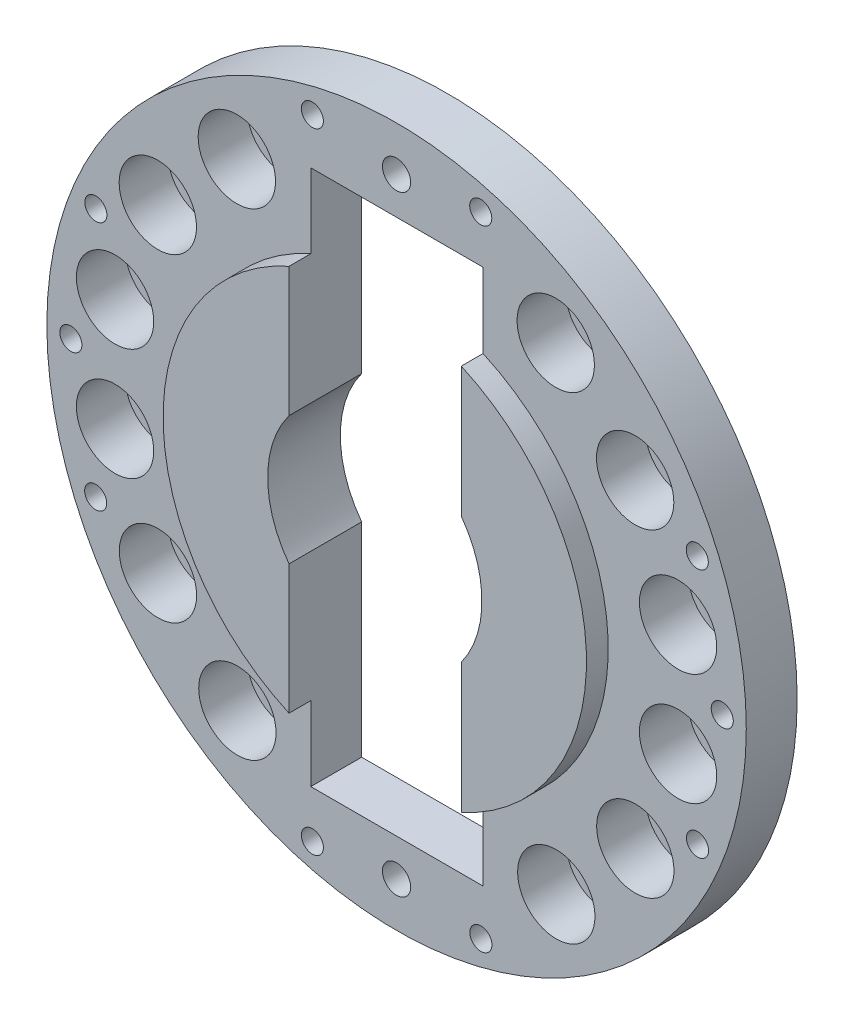
from build123d import *

# Parameters (mm, degrees)
SKETCH1_R                      = 272.79346
SKETCH1_R_2                    = 30.1625
SKETCH1_R_3                    = 8.617585
SKETCH1_R_4                    = 11.00963
SKETCH1_R_5                    = 164.44976
SKETCH1_R_6                    = 83.56346
EXTRUDE5_DEPTH                 = 39.69258
EXTRUDE8_DEPTH                 = 16.97482
SKETCH4_W                      = 134.3533
SKETCH4_H                      = 418.01542
EXTRUDE10_DEPTH                = 64.83223
SKETCH7_R                      = 30.1625
EXTRUDE12_DEPTH                = 1.59258
F_1_8_TAPPED_HOLE1_D           = 22.225
F_1_8_TAPPED_HOLE1_ON_FACE_2_D = 22.225


with BuildPart() as part:
    # Sketch1 → Extrude5 (new body)
    with BuildSketch(Plane.XY):
        Circle(SKETCH1_R)
        with Locations((219.584848865, -43.672962802)):
            Circle(SKETCH1_R_2, mode=Mode.SUBTRACT)
        with Locations((-219.57722315, 43.711286923)):
            Circle(SKETCH1_R_2, mode=Mode.SUBTRACT)
        with Locations((186.220609513, -124.284826602)):
            Circle(SKETCH1_R_2, mode=Mode.SUBTRACT)
        with Locations((-186.220609513, 124.284826602)):
            Circle(SKETCH1_R_2, mode=Mode.SUBTRACT)
        with Locations((124.588226536, -186.017760817)):
            Circle(SKETCH1_R_2, mode=Mode.SUBTRACT)
        with Locations((-124.588226536, 186.017760817)):
            Circle(SKETCH1_R_2, mode=Mode.SUBTRACT)
        with Locations((-124.160317609, -186.303647474)):
            Circle(SKETCH1_R_2, mode=Mode.SUBTRACT)
        with Locations((124.160317609, 186.303647474)):
            Circle(SKETCH1_R_2, mode=Mode.SUBTRACT)
        with Locations((-186.104477248, -124.458656103)):
            Circle(SKETCH1_R_2, mode=Mode.SUBTRACT)
        with Locations((186.104477248, 124.458656103)):
            Circle(SKETCH1_R_2, mode=Mode.SUBTRACT)
        with Locations((219.584848865, 43.672962802)):
            Circle(SKETCH1_R_2, mode=Mode.SUBTRACT)
        with Locations((-219.584848865, -43.672962802)):
            Circle(SKETCH1_R_2, mode=Mode.SUBTRACT)
        with Locations((-234.688092884, -97.272902019)):
            Circle(SKETCH1_R_3, mode=Mode.SUBTRACT)
        with Locations((-65.668151158, -245.414368635)):
            Circle(SKETCH1_R_3, mode=Mode.SUBTRACT)
        with Locations((65.779081624, -245.384658913)):
            Circle(SKETCH1_R_3, mode=Mode.SUBTRACT)
        with Locations((234.735092644, -97.159429242)):
            Circle(SKETCH1_R_3, mode=Mode.SUBTRACT)
        with Locations((-234.564955174, 97.569463528)):
            Circle(SKETCH1_R_3, mode=Mode.SUBTRACT)
        with Locations((-65.668151158, 245.414368635)):
            Circle(SKETCH1_R_3, mode=Mode.SUBTRACT)
        with Locations((65.668151158, 245.414368635)):
            Circle(SKETCH1_R_3, mode=Mode.SUBTRACT)
        with Locations((234.564955174, 97.569463528)):
            Circle(SKETCH1_R_3, mode=Mode.SUBTRACT)
        with Locations((254.04826, 0)):
            Circle(SKETCH1_R_3, mode=Mode.SUBTRACT)
        with Locations((-254.04826, 0)):
            Circle(SKETCH1_R_3, mode=Mode.SUBTRACT)
        with Locations((0, -238.00054)):
            Circle(SKETCH1_R_4, mode=Mode.SUBTRACT)
        with Locations((0, 238.00054)):
            Circle(SKETCH1_R_4, mode=Mode.SUBTRACT)
        Circle(SKETCH1_R_5, mode=Mode.SUBTRACT)
        Circle(SKETCH1_R_5)
        Circle(SKETCH1_R_6, mode=Mode.SUBTRACT)
    extrude(amount=EXTRUDE5_DEPTH)

    # Sketch3 → Extrude8 (add)
    with BuildSketch(Plane.XY.offset(39.69258)):
        with BuildLine():
            Line((-66.9036, 150.950693964), (-66.9036, 50.067555904))
            ThreePointArc((-66.9036, 50.067555904), (-83.56346, 0), (-66.9036, -50.067555904))
            Line((-66.9036, -50.067555904), (-66.9036, -150.950693964))
            ThreePointArc((-66.9036, -150.950693964), (-165.1127, 0), (-66.9036, 150.950693964))
        make_face()
        with BuildLine():
            Line((67.4497, 150.707470522), (67.4497, 49.329401143))
            ThreePointArc((67.4497, 49.329401143), (83.56346, 0), (67.4497, -49.329401143))
            Line((67.4497, -49.329401143), (67.4497, -150.707470522))
            ThreePointArc((67.4497, -150.707470522), (165.1127, 0), (67.4497, 150.707470522))
        make_face()
    extrude(amount=EXTRUDE8_DEPTH)

    # Sketch4 → Extrude10 (cut)
    with BuildSketch(Plane.XY.offset(56.6674)):
        with Locations((0.27305, 0)):
            Rectangle(SKETCH4_W, SKETCH4_H)
    extrude(amount=-EXTRUDE10_DEPTH, mode=Mode.SUBTRACT)

    # Sketch7 → Extrude12 (add)
    with BuildSketch(Plane(origin=(0, 0, 0), x_dir=(-1, 0, 0), z_dir=(0, 0, -1))):
        with Locations((-124.160317609, 186.303647474)):
            Circle(SKETCH7_R)
        with Locations((-186.104477248, 124.458656103)):
            Circle(SKETCH7_R)
        with Locations((-219.584848865, 43.672962802)):
            Circle(SKETCH7_R)
        with Locations((-219.584848865, -43.672962802)):
            Circle(SKETCH7_R)
        with Locations((-186.220609513, -124.284826602)):
            Circle(SKETCH7_R)
        with Locations((-124.588226536, -186.017760817)):
            Circle(SKETCH7_R)
        with Locations((124.160317609, -186.303647474)):
            Circle(SKETCH7_R)
        with Locations((186.104477248, -124.458656103)):
            Circle(SKETCH7_R)
        with Locations((219.584848865, -43.672962802)):
            Circle(SKETCH7_R)
        with Locations((219.57722315, 43.711286923)):
            Circle(SKETCH7_R)
        with Locations((186.220609513, 124.284826602)):
            Circle(SKETCH7_R)
        with Locations((124.588226536, 186.017760817)):
            Circle(SKETCH7_R)
    extrude(amount=-EXTRUDE12_DEPTH)

    # 1-8 Tapped Hole1 (through all)
    with Locations(Plane(origin=(124.160317609, 186.303647474, 39.69258), x_dir=(1, 0, 0), z_dir=(0, 0, 1))):
        with Locations((0, 0), (95.424531256, -142.630684672), (95.424531256, -229.976610276), (62.060291904, -310.588474076), (0.427908927, -372.321408291), (-310.264794857, -310.762303577), (-310.380927122, -62.018820872)):
            Hole(F_1_8_TAPPED_HOLE1_D / 2)

    # 1-8 Tapped Hole1 on face 2 (through all)
    with Locations(Plane(origin=(124.160317609, 186.303647474, 1.59258), x_dir=(1, 0, 0), z_dir=(0, 0, 1))):
        with Locations((0, 0), (61.944159639, -61.844991371), (-248.320635218, -372.607294948), (-343.745166474, -229.976610276), (-343.737540759, -142.592360551), (-248.748544145, -0.285886657)):
            Hole(F_1_8_TAPPED_HOLE1_ON_FACE_2_D / 2)


solid = part.part
